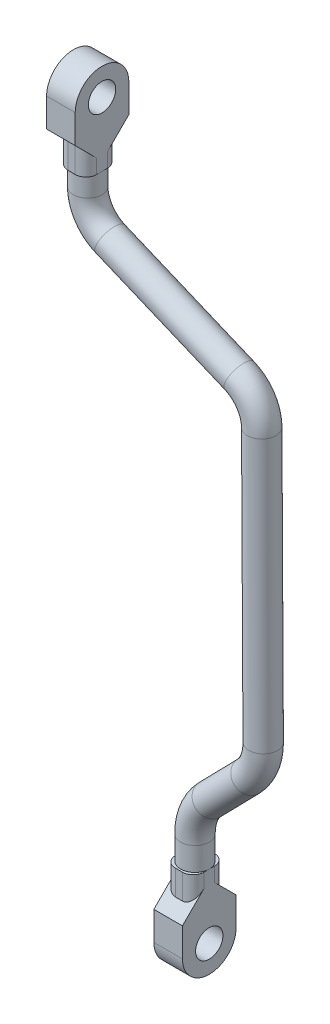
from build123d import *

# Parameters (mm, degrees)
SKETCH1_R           = 3.824529863
BOSS_EXTRUDE1_DEPTH = 8
FILLET1_R           = 3
SKETCH4_R           = 3.824529863
BOSS_EXTRUDE3_DEPTH = 8
SKETCH5_R           = 4
FILLET3_R           = 3


with BuildPart() as part:
    # Sketch1 → Boss-Extrude1 (new body)
    with BuildSketch(Plane(origin=(0, 0, 0), x_dir=(0, 0, -1), z_dir=(1, 0, 0))):
        with BuildLine():
            Line((0, 92), (0, 99))
            Line((0, 99), (-3, 102))
            Line((-3, 102), (-3, 110))
            ThreePointArc((-3, 110), (4.5, 117.5), (12, 110))
            Line((12, 110), (12, 102))
            Line((12, 102), (9, 99))
            Line((9, 99), (9, 92))
            Line((9, 92), (0, 92))
        make_face()
        with Locations((4.5, 110)):
            Circle(SKETCH1_R, mode=Mode.SUBTRACT)
    extrude(amount=BOSS_EXTRUDE1_DEPTH)

    # Fillet1
    fillet1_edges = [part.edges().sort_by_distance(p)[0] for p in [
        (0, 95.5, -9),
        (8, 95.5, 0),
        (8, 95.5, -9),
        (0, 95.5, 0),
    ]]
    fillet(fillet1_edges, radius=FILLET1_R)



with BuildPart() as body_2:
    # Sketch4 → Boss-Extrude3 (new body)
    with BuildSketch(Plane(origin=(30, 0, 0), x_dir=(0, 0, -1), z_dir=(1, 0, 0))):
        with BuildLine():
            Line((-0.004228731, -61.999999953), (8.995771269, -61.999999953))
            Line((8.995771269, -61.999999953), (8.995771269, -68.999999953))
            Line((8.995771269, -68.999999953), (11.995771269, -71.999999953))
            Line((11.995771269, -71.999999953), (11.995771269, -79.999999953))
            ThreePointArc((11.995771269, -79.999999953), (4.495771269, -87.499999953), (-3.004228731, -79.999999953))
            Line((-3.004228731, -79.999999953), (-3.004228731, -71.999999953))
            Line((-3.004228731, -71.999999953), (-0.004228731, -68.999999953))
            Line((-0.004228731, -68.999999953), (-0.004228731, -61.999999953))
        make_face()
        with Locations((4.495771269, -79.999999953)):
            Circle(SKETCH4_R, mode=Mode.SUBTRACT)
    extrude(amount=BOSS_EXTRUDE3_DEPTH)


with BuildPart() as part_1:
    add(part.part)

    add(body_2.part)  # Sweep1 merges body 2
    # Sweep1: sweep along a curve in space
    with BuildLine() as sweep1_path:
        Line((4, 92, -4.5), (4, 86.352130242, -4.5))
        ThreePointArc((4, 86.352130242, -4.5), (5.755444944, 80.69219678, -4.459942659), (10.405301947, 77.019920921, -4.353837987))
        Line((10.405301947, 77.019920921, -4.353837987), (47.364863067, 62.786270522, -3.510461064))
        ThreePointArc((47.364863067, 62.786270522, -3.510461064), (52.019060491, 59.108139902, -3.416609062), (53.77123923, 53.439910597, -3.409333713))
        Line((53.77123923, 53.439910597, -3.409333713), (53.673864596, -23.127444485, -3.913324031))
        ThreePointArc((49.40348763, -33.590655921, -4.071020723), (52.56170451, -28.776861802, -3.973565781), (53.673864596, -23.127444485, -3.913324031))
        Line((38.271359037, -44.984282045, -4.377988717), (49.40348763, -33.590655921, -4.071020723))
        ThreePointArc((34, -55.469085278, -4.495771269), (35.108839506, -49.80804563, -4.465195064), (38.271359037, -44.984282045, -4.377988717))
        Line((34, -61.999999953, -4.495771269), (34, -55.469085278, -4.495771269))
    # Sketch5 → Sweep1 (sweep)
    with BuildSketch(Plane.XZ.offset(-92)):
        with Locations((4, -4.5)):
            Circle(SKETCH5_R)
    sweep(path=sweep1_path.line)

    # Fillet3
    fillet3_edges = [part_1.edges().sort_by_distance(p)[0] for p in [
        (38, -65.499999953, -8.995771269),
        (38, -65.499999953, 0.004228731),
        (30, -65.499999953, -8.995771269),
        (30, -65.499999953, 0.004228731),
    ]]
    fillet(fillet3_edges, radius=FILLET3_R)


solid = part_1.part
